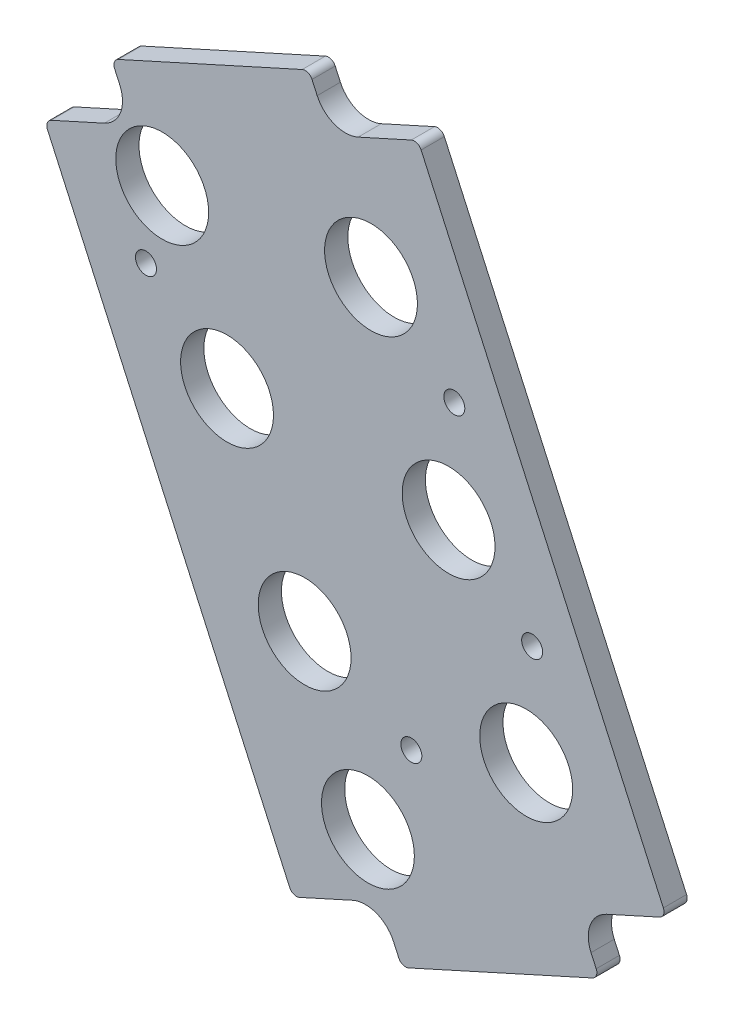
from build123d import *

# Parameters (mm, degrees)
BOSS_EXTRUDE1_DEPTH   = 4.7625
F_6_CLEARANCE_HOLE1_D = 4.3053
SKETCH6_R             = 9.525
CUT_EXTRUDE1_DEPTH    = 5.7625


with BuildPart() as part:
    # Sketch1 → Boss-Extrude1 (new body)
    with BuildSketch(Plane.XY):
        with BuildLine():
            Line((61.328308874, -51.443881834), (72.233641051, -46.509447198))
            ThreePointArc((72.233641051, -46.509447198), (73.031430575, -45.658526875), (72.993861427, -44.492712962))
            Line((72.993861427, -44.492712962), (23.309209228, 65.312700679))
            ThreePointArc((23.309209228, 65.312700679), (22.458288905, 66.110490204), (21.292474992, 66.072921056))
            Line((21.292474992, 66.072921056), (10.387142815, 61.13848642))
            ThreePointArc((10.387142815, 61.13848642), (5.529584843, 60.981948303), (1.984083498, 64.306071322))
            Line((1.984083498, 64.306071322), (0.923899929, 66.649126776))
            ThreePointArc((0.923899929, 66.649126776), (0.072979606, 67.4469163), (-1.092834307, 67.409347153))
            Line((-1.092834307, 67.409347153), (-38.813134462, 50.341700559))
            ThreePointArc((-38.813134462, 50.341700559), (-39.610923987, 49.490780236), (-39.573354839, 48.324966323))
            Line((-39.573354839, 48.324966323), (-38.51317127, 45.981910869))
            ThreePointArc((-38.51317127, 45.981910869), (-38.356633153, 41.124352897), (-41.680756172, 37.578851552))
            Line((-41.680756172, 37.578851552), (-52.586088348, 32.644416915))
            ThreePointArc((-52.586088348, 32.644416915), (-53.383877873, 31.793496593), (-53.346308725, 30.627682679))
            Line((-53.346308725, 30.627682679), (-3.661656526, -79.177730962))
            ThreePointArc((-3.661656526, -79.177730962), (-2.810736203, -79.975520486), (-1.64492229, -79.937951338))
            Line((-1.64492229, -79.937951338), (9.260409887, -75.003516702))
            ThreePointArc((9.260409887, -75.003516702), (14.117967859, -74.846978586), (17.663469204, -78.171101604))
            Line((17.663469204, -78.171101604), (18.723652773, -80.514157058))
            ThreePointArc((18.723652773, -80.514157058), (19.574573096, -81.311946583), (20.740387009, -81.274377435))
            Line((20.740387009, -81.274377435), (58.460687164, -64.206730842))
            ThreePointArc((58.460687164, -64.206730842), (59.258476689, -63.355810519), (59.220907541, -62.189996606))
            Line((59.220907541, -62.189996606), (58.160723972, -59.846941151))
            ThreePointArc((58.160723972, -59.846941151), (58.004185856, -54.989383179), (61.328308874, -51.443881834))
        make_face()
    extrude(amount=BOSS_EXTRUDE1_DEPTH)

    # #6 Clearance Hole1 (through all)
    with Locations(Plane.XY.offset(4.7625)):
        with Locations((30.114722566, 23.855073088), (46.082919532, -11.435391781), (-33.128884005, 16.984419854), (21.298547528, -42.304619004)):
            Hole(F_6_CLEARANCE_HOLE1_D / 2)

    # Sketch6 → Cut-Extrude1 (cut, through all)
    with BuildSketch(Plane.XY.offset(4.7625)):
        with Locations((13.026989476, 37.590195142)):
            Circle(SKETCH6_R)
        with Locations((28.942831698, 2.415436715)):
            Circle(SKETCH6_R)
        with Locations((44.858673919, -32.759321712)):
            Circle(SKETCH6_R)
        with Locations((-16.503976684, 3.039878823)):
            Circle(SKETCH6_R)
        with Locations((-0.588134462, -32.134879603)):
            Circle(SKETCH6_R)
        with Locations((-29.802081698, 32.42931514)):
            Circle(SKETCH6_R)
        with Locations((12.395842088, -60.830077267)):
            Circle(SKETCH6_R)
    extrude(amount=-CUT_EXTRUDE1_DEPTH, mode=Mode.SUBTRACT)


solid = part.part
